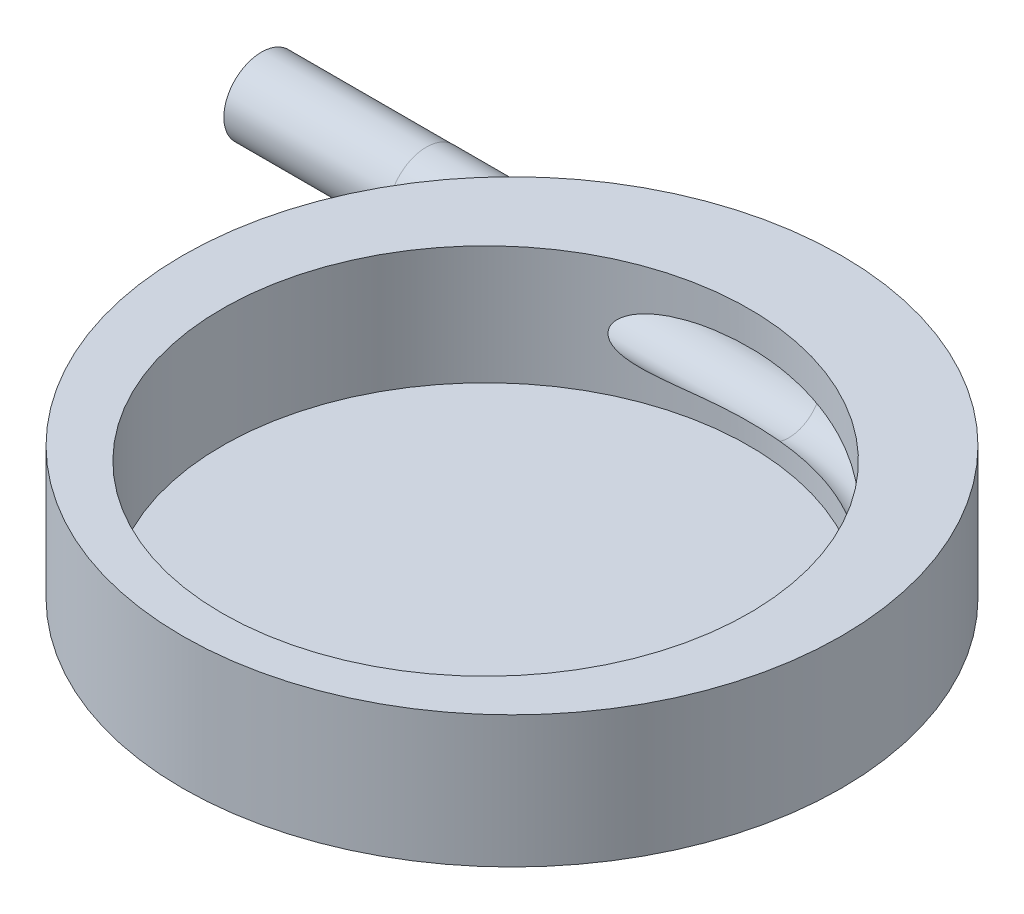
from build123d import *

# Parameters (mm, degrees)
SKETCH1_R                = 50
SKETCH1_R_2              = 40
BOSS_EXTRUDE1_DEPTH      = 20
BOSS_EXTRUDE2_DEPTH      = 2
BOSS_EXTRUDE2_DEPTH_BACK = 4
SKETCH2_R                = 40
SKETCH4_R                = 5.75
SKETCH4_R_2              = 4.75
SKETCH7_R                = 5
SKETCH8_R                = 5.718396741
SKETCH8_R_2              = 4.973304453
BOSS_EXTRUDE4_DEPTH      = 25


with BuildPart() as part:
    # Sketch1 → Boss-Extrude1 (new body)
    with BuildSketch(Plane(origin=(0, 0, 0), x_dir=(1, 0, 0), z_dir=(0, 1, 0))):
        with Locations(Location((0, 0, 0), (0, 0, 270))):
            Circle(SKETCH1_R)
        with Locations(Location((0, -4, 0), (0, 0, 270))):
            Circle(SKETCH1_R_2, mode=Mode.SUBTRACT)
    extrude(amount=BOSS_EXTRUDE1_DEPTH)

    # Sketch2 → Boss-Extrude2 (add, two sides: drawn at the far end of the back side and taken through both)
    with BuildSketch(Plane(origin=(0, 0, 0), x_dir=(1, 0, 0), z_dir=(0, 1, 0)).offset(-BOSS_EXTRUDE2_DEPTH_BACK)):
        with Locations(Location((0, -4, 0), (0, 0, 270))):
            Circle(SKETCH2_R)
    extrude(amount=BOSS_EXTRUDE2_DEPTH + BOSS_EXTRUDE2_DEPTH_BACK)

    # Sweep1: sweep along a path in Sketch5
    with BuildLine(Plane(origin=(0, 0, 0), x_dir=(1, 0, 0), z_dir=(0, 1, 0))) as sweep1_path:
        Line((-50, 37), (-20.098494214, 37))
    # Sketch4 → Sweep1 (sweep)
    with BuildSketch(Plane.ZY.offset(50)):
        with Locations((-37, 10)):
            Circle(SKETCH4_R)
        with Locations((-37, 10)):
            Circle(SKETCH4_R_2, mode=Mode.SUBTRACT)
    sweep(path=sweep1_path.line)

    # Cut-Sweep4: sweep along a path in Sketch6
    with BuildLine(Plane(origin=(0, 0, 0), x_dir=(1, 0, 0), z_dir=(0, 1, 0))) as cut_sweep4_path:
        Line((-50, 41), (5, 41))
        ThreePointArc((5, 41), (42.343632049, 16.047782803), (33.581578579, -28.002034639))
    # Sketch7 → Cut-Sweep4 (sweep, cut)
    with BuildSketch(Plane.ZY.offset(50)):
        with Locations((-37, 10.053836195)):
            Circle(SKETCH7_R)
    sweep(path=cut_sweep4_path.line, mode=Mode.SUBTRACT)

    # Sketch8 → Boss-Extrude4 (add)
    with BuildSketch(Plane.ZY.offset(50)):
        with Locations(Location((-36.988861594, 10.029575359, 0), (0, 0, 69.358502731))):
            Circle(SKETCH8_R)
        with Locations(Location((-36.988861594, 10.029575359, 0), (0, 0, 294.660355781))):
            Circle(SKETCH8_R_2, mode=Mode.SUBTRACT)
    extrude(amount=BOSS_EXTRUDE4_DEPTH)


solid = part.part
